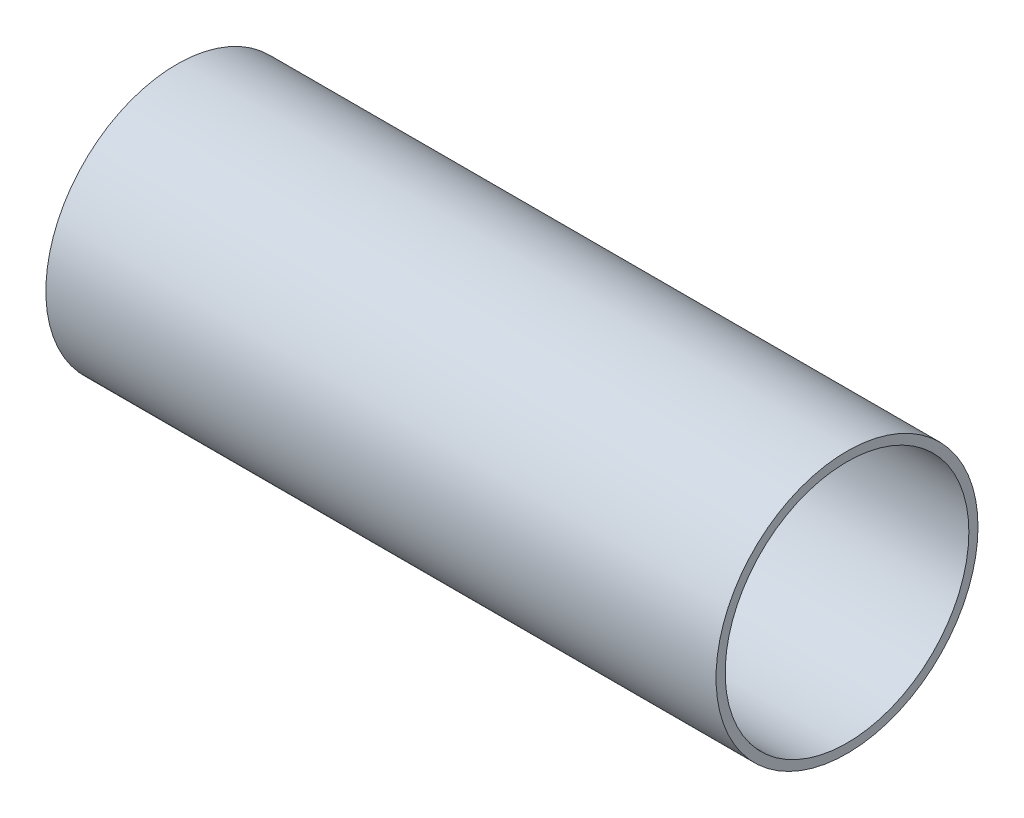
from build123d import *

# Parameters (mm, degrees)
SKETCH1_R           = 27.305
SKETCH1_R_2         = 25.4
BOSS_EXTRUDE1_DEPTH = 69.85


with BuildPart() as part:
    # Sketch1 → Boss-Extrude1 (new body, symmetric)
    with BuildSketch(Plane(origin=(0, 0, 0), x_dir=(0, 0, -1), z_dir=(1, 0, 0))):
        Circle(SKETCH1_R)
        Circle(SKETCH1_R_2, mode=Mode.SUBTRACT)
    extrude(amount=BOSS_EXTRUDE1_DEPTH, both=True)


solid = part.part
